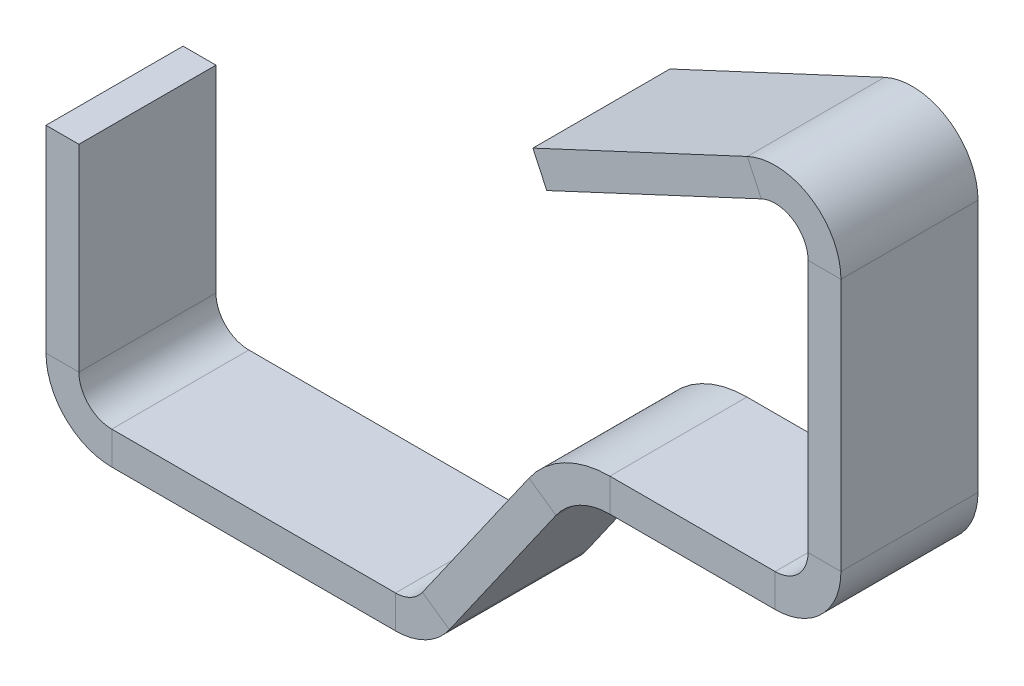
from build123d import *

# Parameters (mm, degrees)
SKETCH2_W = 6
SKETCH2_H = 25


with BuildPart() as part:
    # Sweep1: sweep along a path in Sketch1
    with BuildLine(Plane.XY) as sweep1_path:
        Line((0, 0), (0, -36))
        ThreePointArc((0, -36), (3.514718626, -44.485281374), (12, -48))
        Line((12, -48), (63.753195393, -48))
        ThreePointArc((63.753195393, -48), (69.294178752, -46.644129998), (73.583019925, -42.882917236))
        Line((73.583019925, -42.882917236), (93.024866527, -15.117082764))
        ThreePointArc((93.024866527, -15.117082764), (97.3137077, -11.355870002), (102.854691059, -10))
        Line((102.854691059, -10), (133, -10))
        ThreePointArc((133, -10), (141.485281374, -6.485281374), (145, 2))
        Line((145, 2), (145, 48.163773075))
        ThreePointArc((145, 48.163773075), (139.4475953, 58.284470424), (127.928580859, 59.039466519))
        Line((127.928580859, 59.039466519), (88.808917204, 40.797667772))
    # Sketch2 → Sweep1 (sweep)
    with BuildSketch(Plane(origin=(0, 0, 0), x_dir=(-1, 0, 0), z_dir=(0, -1, 0))):
        with Locations((-3, 0)):
            Rectangle(SKETCH2_W, SKETCH2_H)
    sweep(path=sweep1_path.line)


solid = part.part
